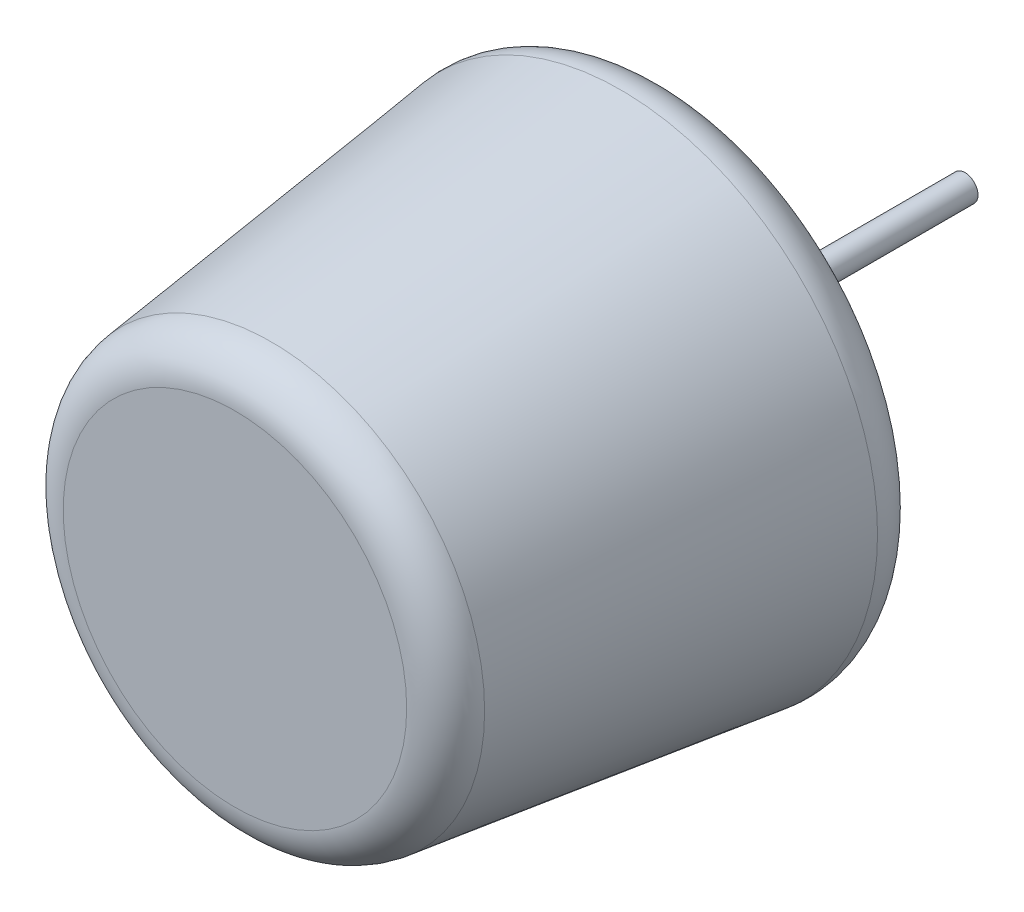
from build123d import *

# Parameters (mm, degrees)
FILLET1_R = 2.54


with BuildPart() as part:
    # Sketch3 → Revolve1 (revolve)
    with BuildSketch(Plane(origin=(0, 0, 0), x_dir=(1, 0, 0), z_dir=(0, 1, 0))):
        Polygon((0, 0), (12.7, 0), (15.875, 25.4), (0.79375, 31.75), (0.79375, 44.45), (0, 44.45), (0, 31.75), (0, 25.4), align=None)
    revolve(axis=Axis((0, 0, 0), (0, 0, -1)))

    # Fillet1
    fillet1_edges = [part.edges().sort_by_distance(p)[0] for p in [
        (-15.875, 0, -25.4),
        (-12.7, 0, 0),
    ]]
    fillet(fillet1_edges, radius=FILLET1_R)


solid = part.part
